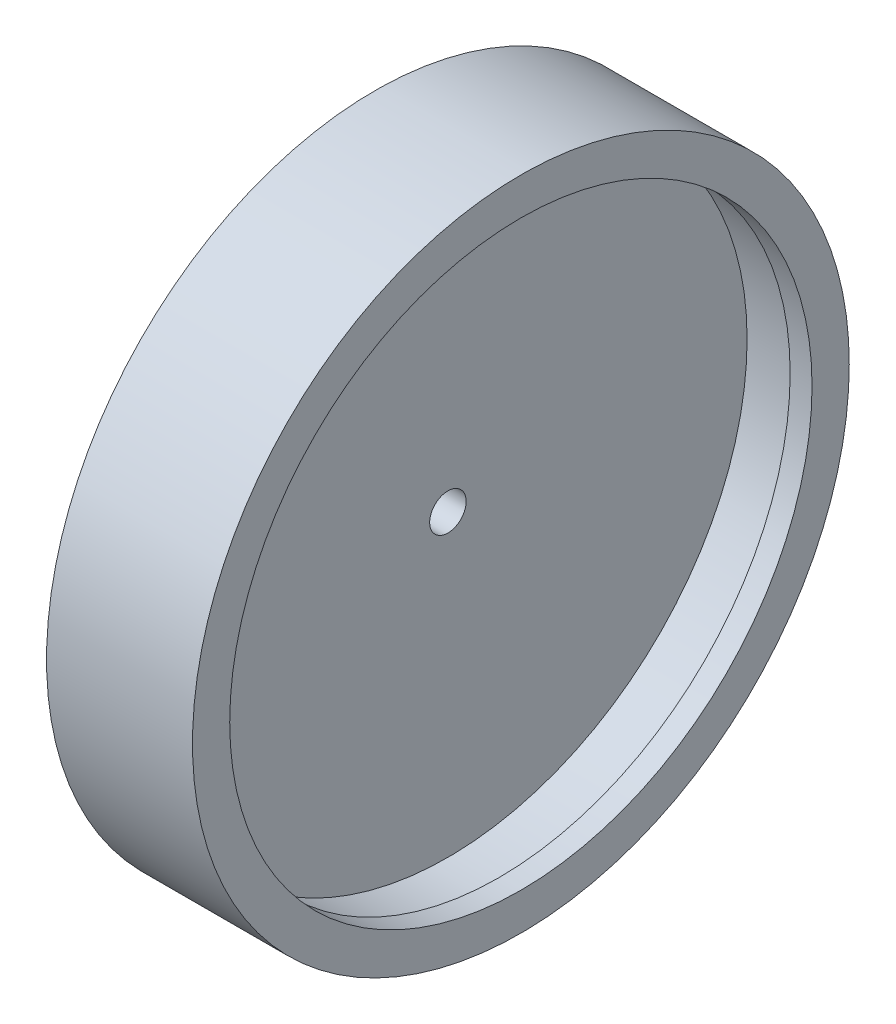
from build123d import *

# Parameters (mm, degrees)
CROQUIS2_R              = 45
CROQUIS2_R_2            = 41
SALIENTE_EXTRUIR1_DEPTH = 10
CROQUIS3_R              = 45
SALIENTE_EXTRUIR2_DEPTH = 10
CROQUIS4_R              = 45
CROQUIS4_R_2            = 39.9
SALIENTE_EXTRUIR3_DEPTH = 3
CROQUIS5_R              = 2.5
CORTAR_EXTRUIR1_DEPTH   = 10


with BuildPart() as part:
    # Croquis2 → Saliente-Extruir1 (new body)
    with BuildSketch(Plane(origin=(0, 0, 0), x_dir=(0, 0, -1), z_dir=(1, 0, 0))):
        with Locations((-3.334066787, 2.439156595)):
            Circle(CROQUIS2_R)
        with Locations((-3.334066787, 2.439156595)):
            Circle(CROQUIS2_R_2, mode=Mode.SUBTRACT)
    extrude(amount=SALIENTE_EXTRUIR1_DEPTH)

    # Croquis3 → Saliente-Extruir2 (add)
    with BuildSketch(Plane(origin=(0, 0, 0), x_dir=(0, 0, -1), z_dir=(1, 0, 0))):
        with Locations((-3.334066787, 2.439156595)):
            Circle(CROQUIS3_R)
    extrude(amount=-SALIENTE_EXTRUIR2_DEPTH)

    # Croquis4 → Saliente-Extruir3 (add)
    with BuildSketch(Plane(origin=(10, 0, 0), x_dir=(0, 0, -1), z_dir=(1, 0, 0))):
        with Locations((-3.334066787, 2.439156595)):
            Circle(CROQUIS4_R)
        with Locations((-3.334066787, 2.439156595)):
            Circle(CROQUIS4_R_2, mode=Mode.SUBTRACT)
    extrude(amount=-SALIENTE_EXTRUIR3_DEPTH)

    # Croquis5 → Cortar-Extruir1 (cut)
    with BuildSketch(Plane(origin=(0, 0, 0), x_dir=(0, 0, -1), z_dir=(1, 0, 0))):
        with Locations((-3.334066787, 2.439156595)):
            Circle(CROQUIS5_R)
    extrude(amount=-CORTAR_EXTRUIR1_DEPTH, mode=Mode.SUBTRACT)


solid = part.part
